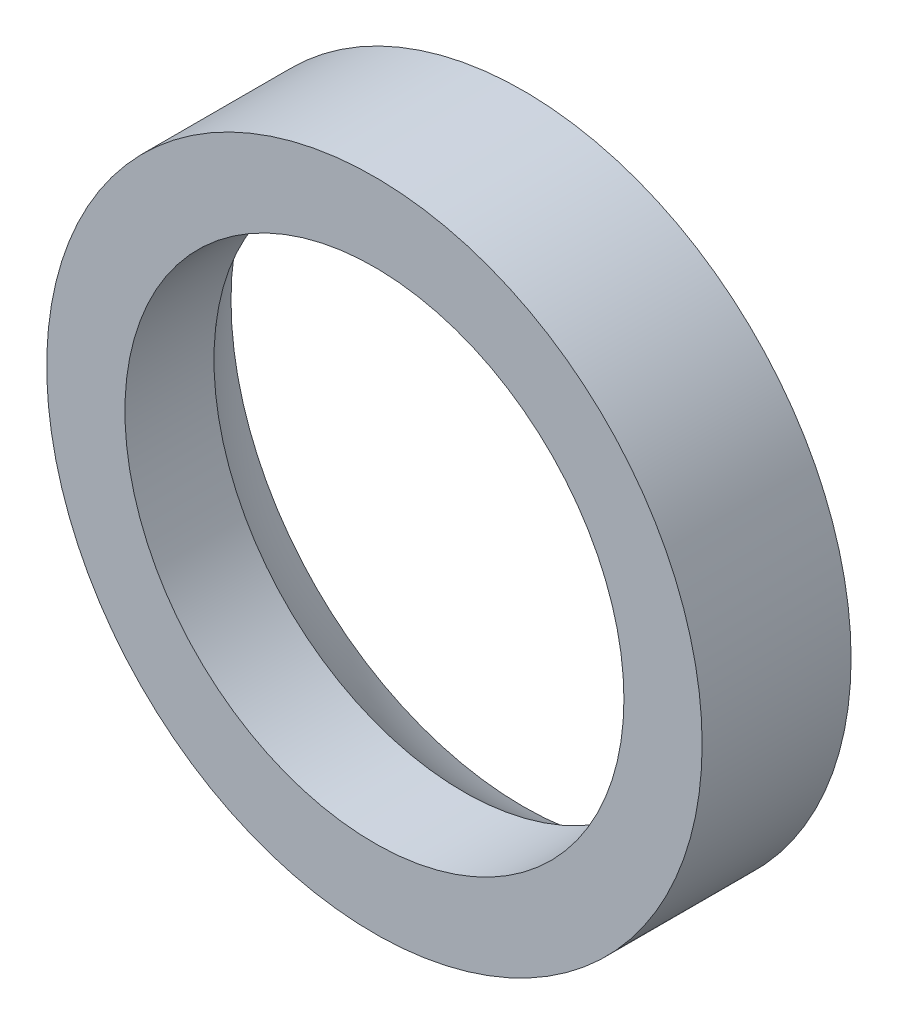
from build123d import *


with BuildPart() as part:
    # Skizze1 → Rotation1 (revolve)
    with BuildSketch(Plane(origin=(0, 0, 0), x_dir=(0, 0, -1), z_dir=(1, 0, 0))):
        with BuildLine():
            Line((-2, 4.4), (-2, 3.35))
            Line((-2, 3.35), (-0.804579838, 3.35))
            ThreePointArc((-0.804579838, 3.35), (-0.418153809, 3.659955004), (0, 3.925557285))
            Line((0, 3.925557285), (0, 4.4))
            Line((0, 4.4), (-2, 4.4))
        make_face()
    revolve(axis=Axis((0, 0, 0), (0, 0, 1)))


solid = part.part
